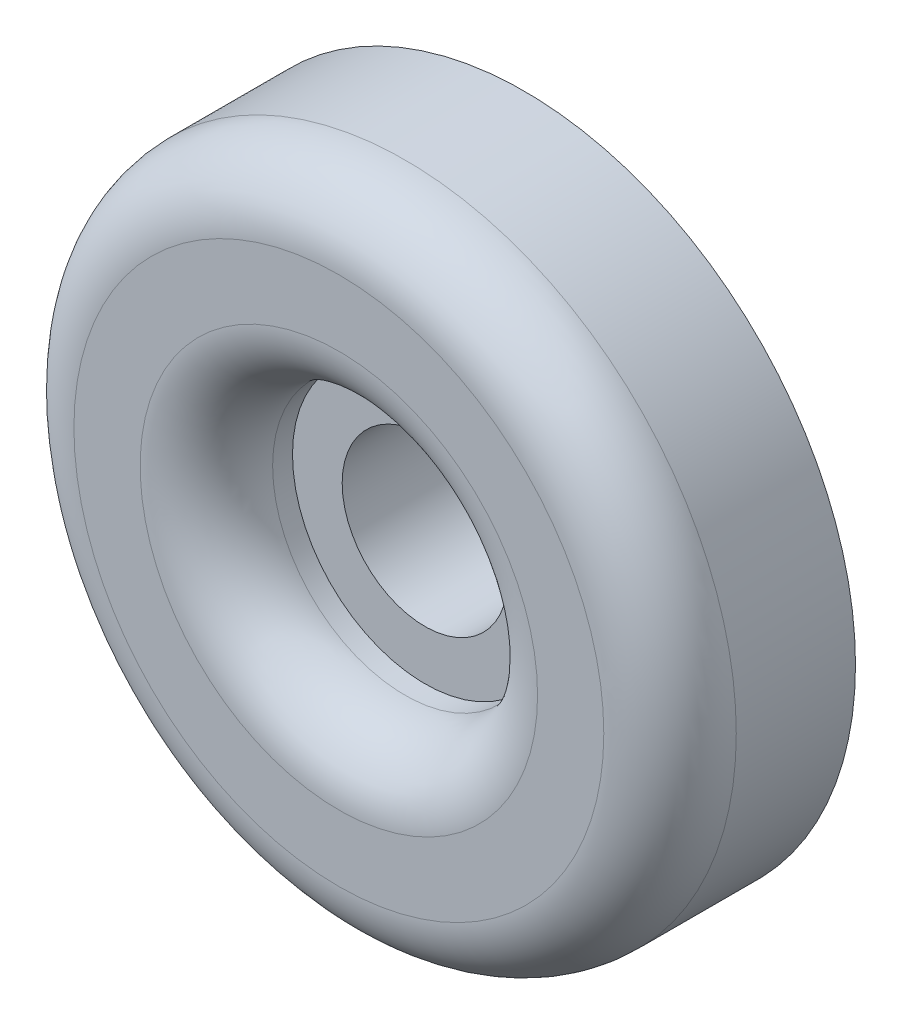
from build123d import *

# Parameters (mm, degrees)
SKETCH1_R           = 12.7
SKETCH1_R_2         = 3.175
BOSS_EXTRUDE1_DEPTH = 3.81
SKETCH2_R           = 12.7
SKETCH2_R_2         = 5.08
BOSS_EXTRUDE2_DEPTH = 3.302
FILLET2_R           = 2.54


with BuildPart() as part:
    # Sketch1 → Boss-Extrude1 (new body)
    with BuildSketch(Plane(origin=(0, 0, 0), x_dir=(0, 1, 0), z_dir=(0, 0, 1))):
        with Locations(Location((0, 0, 0), (0, 0, 90))):
            Circle(SKETCH1_R)
        with Locations(Location((0, 0, 0), (0, 0, 90))):
            Circle(SKETCH1_R_2, mode=Mode.SUBTRACT)
    extrude(amount=BOSS_EXTRUDE1_DEPTH)

    # Sketch2 → Boss-Extrude2 (add)
    with BuildSketch(Plane.XY.offset(3.81)):
        with Locations(Location((0, 0, 0), (0, 0, 180))):
            Circle(SKETCH2_R)
        with Locations(Location((0, 0, 0), (0, 0, 180))):
            Circle(SKETCH2_R_2, mode=Mode.SUBTRACT)
    extrude(amount=BOSS_EXTRUDE2_DEPTH)

    # Fillet2
    fillet2_edges = [part.edges().sort_by_distance(p)[0] for p in [
        (12.7, 0, 7.112),
        (5.08, 0, 7.112),
    ]]
    fillet(fillet2_edges, radius=FILLET2_R)


solid = part.part
